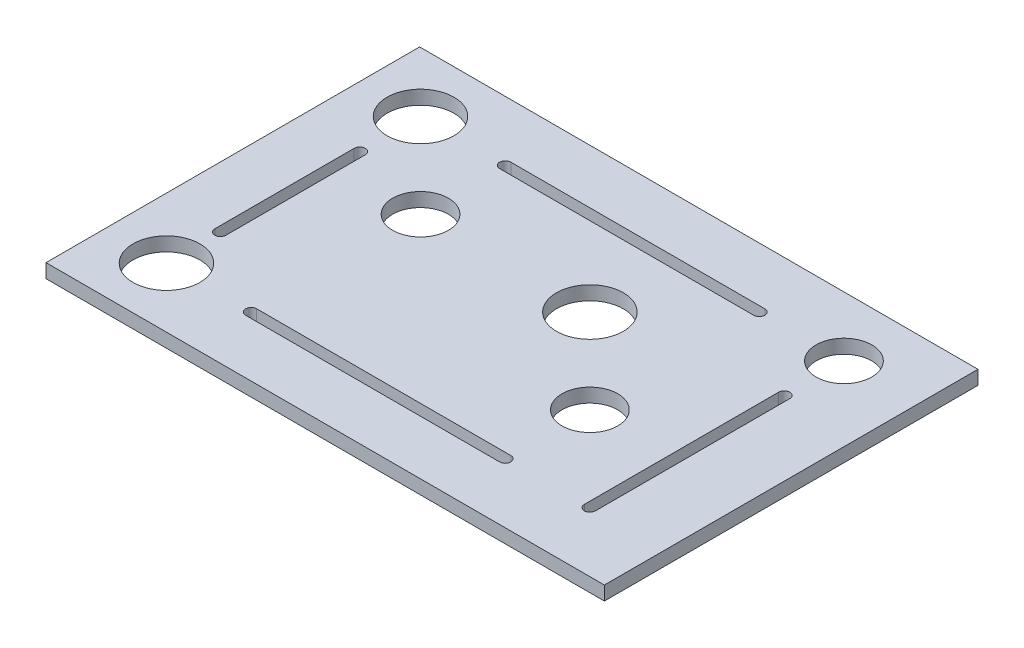
from build123d import *

# Parameters (mm, degrees)
SKETCH1_W           = 127.25
SKETCH1_H           = 85.15
BOSS_EXTRUDE1_DEPTH = 3.175
SKETCH2_R           = 6.35
CUT_EXTRUDE1_DEPTH  = 4.175
SKETCH3_R           = 7.62
SKETCH3_R_2         = 6.35
CUT_EXTRUDE2_DEPTH  = 4.175
CUT_EXTRUDE3_DEPTH  = 4.175


with BuildPart() as part:
    # Sketch1 → Boss-Extrude1 (new body)
    with BuildSketch(Plane(origin=(0, 0, 0), x_dir=(1, 0, 0), z_dir=(0, 1, 0))):
        with Locations((-63.625, 42.575)):
            Rectangle(SKETCH1_W, SKETCH1_H)
    extrude(amount=BOSS_EXTRUDE1_DEPTH)

    # Sketch2 → Cut-Extrude1 (cut, through all)
    with BuildSketch(Plane(origin=(0, 3.175, 0), x_dir=(1, 0, 0), z_dir=(0, 1, 0))):
        with Locations((-16.925, 71.525)):
            Circle(SKETCH2_R)
    extrude(amount=-CUT_EXTRUDE1_DEPTH, mode=Mode.SUBTRACT)

    # Sketch3 → Cut-Extrude2 (cut, through all)
    with BuildSketch(Plane(origin=(0, 0, 0), x_dir=(-1, 0, 0), z_dir=(0, -1, 0))):
        with Locations((113.425, 71.525)):
            Circle(SKETCH3_R)
        with Locations((113.425, 13.625)):
            Circle(SKETCH3_R)
        with Locations((94.125, 52.225)):
            Circle(SKETCH3_R_2)
        with Locations((55.525, 52.225)):
            Circle(SKETCH3_R)
        with Locations((36.225, 32.925)):
            Circle(SKETCH3_R_2)
    extrude(amount=-CUT_EXTRUDE2_DEPTH, mode=Mode.SUBTRACT)

    # Sketch4 → Cut-Extrude3 (cut, through all)
    with BuildSketch(Plane(origin=(0, 3.175, 0), x_dir=(1, 0, 0), z_dir=(0, 1, 0))):
        with BuildLine():
            Line((-18.195, 13.625), (-18.195, 57.914006297))
            ThreePointArc((-18.195, 57.914006297), (-16.925, 59.184006297), (-15.655, 57.914006297))
            Line((-15.655, 57.914006297), (-15.655, 13.625))
            ThreePointArc((-15.655, 13.625), (-16.925, 12.355), (-18.195, 13.625))
        make_face()
        with BuildLine():
            Line((-36.225, 70.255), (-94.125, 70.255))
            ThreePointArc((-94.125, 70.255), (-95.395, 71.525), (-94.125, 72.795))
            Line((-94.125, 72.795), (-36.225, 72.795))
            ThreePointArc((-36.225, 72.795), (-34.955, 71.525), (-36.225, 70.255))
        make_face()
        with BuildLine():
            Line((-114.695, 25.905281506), (-114.695, 57.683208878))
            ThreePointArc((-114.695, 57.683208878), (-113.425, 58.953208878), (-112.155, 57.683208878))
            Line((-112.155, 57.683208878), (-112.155, 25.905281506))
            ThreePointArc((-112.155, 25.905281506), (-113.425, 24.635281506), (-114.695, 25.905281506))
        make_face()
        with BuildLine():
            Line((-36.225, 14.895), (-94.125, 14.895))
            ThreePointArc((-94.125, 14.895), (-95.395, 13.625), (-94.125, 12.355))
            Line((-94.125, 12.355), (-36.225, 12.355))
            ThreePointArc((-36.225, 12.355), (-34.955, 13.625), (-36.225, 14.895))
        make_face()
    extrude(amount=-CUT_EXTRUDE3_DEPTH, mode=Mode.SUBTRACT)


solid = part.part
